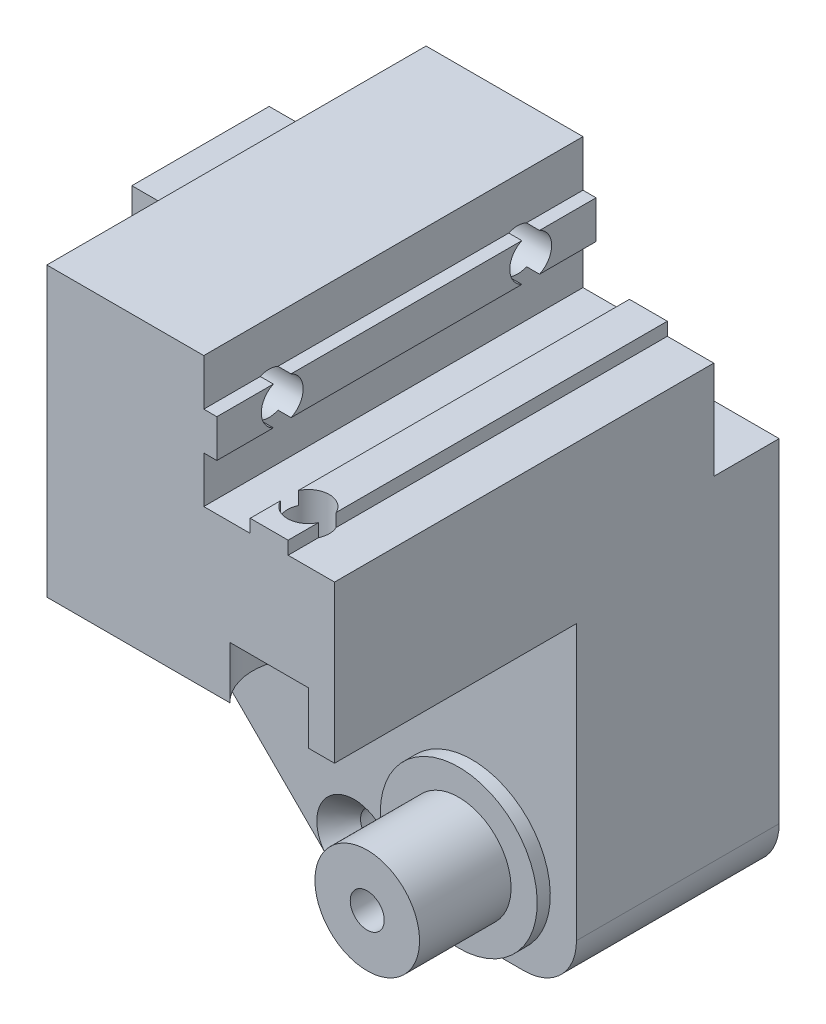
from build123d import *

# Parameters (mm, degrees)
BASE_SKETCHUP_W                   = 34
BASE_SKETCHUP_H                   = 37
BASE_EXTRUSION_DEPTH              = 15.5
FIX_EXTRUSION_DEPTH               = 34
BALL_EXTRUSION_DEPTH              = 29
BALL_BEARING_BASE_SKETCHUP_R      = 6
BALL_BEARING_BASE_EXTRUSION_DEPTH = 1
BALL_BEARING_SKETCHUP_R           = 4
BALL_BEARING_EXTRUSION_DEPTH      = 7
BALL_BEARING_FIX_SKETCHUP_R       = 1.3
BALL_BEARING_FIX_HOLE_DEPTH       = 12
BOSS_EXTRU_5_DEPTH                = 11.5
BOSS_EXTRU_6_DEPTH                = 1
ESQUISSE13_W                      = 5
ESQUISSE13_H                      = 17.5
ENL_V_MAT_EXTRU_1_DEPTH           = 35
CONG_2_R                          = 4
ENL_V_MAT_EXTRU_2_DEPTH           = 16.5
CONG_4_R                          = 2
ESQUISSE16_R                      = 1.6
MAKERBEAMINTERIORHOLES1_DEPTH     = 23
ESQUISSE17_R                      = 4.25
MAKERBEAMINTERIORHOLES2_DEPTH     = 4
ESQUISSE18_R                      = 1.6
MAKERBEAMFRONTHOLE1_DEPTH         = 23
ESQUISSE19_R                      = 4.25
MAKERBEAMFRONTHOLE2_DEPTH         = 4
ESQUISSE20_W                      = 37
ESQUISSE20_H                      = 47
ENL_V_MAT_EXTRU_7_DEPTH           = 35


with BuildPart() as part:
    # Base Sketchup → Base Extrusion (new body)
    with BuildSketch(Plane.XY):
        Rectangle(BASE_SKETCHUP_W, BASE_SKETCHUP_H)
    extrude(amount=BASE_EXTRUSION_DEPTH)


with BuildPart() as body_2:
    # Fix Sketchup → Fix Extrusion (new body)
    with BuildSketch(Plane(origin=(0, 0, 0), x_dir=(-1, 0, 0), z_dir=(0, 0, -1))):
        Polygon((17, 18.5), (13.45, 18.5), (13.45, 19.5), (10.55, 19.5), (10.55, 18.5), (7, 18.5), (7, 22.05), (8, 22.05), (8, 24.95), (7, 24.95), (7, 28.5), (-5, 28.5), (-5, 6.5), (17, 6.5), align=None)
    extrude(amount=-FIX_EXTRUSION_DEPTH)


with BuildPart() as ball_extrusion_tool:
    # Ball Place Sketchup → Ball Extrusion (new body)
    with BuildSketch(Plane.XZ.offset(18.5)):
        Polygon((-12.25, 0), (-12.25, 8.25), (-11.75, 8.25), (-11.75, 9.25), (-12.25, 9.25), (-12.25, 11.5), (12.25, 11.5), (12.25, 9.25), (11.75, 9.25), (11.75, 8.25), (12.25, 8.25), (12.25, 0), align=None)
    extrude(amount=-BALL_EXTRUSION_DEPTH)


with BuildPart() as part_1:
    add(part.part)

    # Ball Extrusion: cut by ball_extrusion_tool
    add(ball_extrusion_tool.part, mode=Mode.SUBTRACT)

    # Esquisse12 → Fraisage pour vis à tête fraisée bombée #41 (revolve, cut)
    with BuildSketch(Plane(origin=(0, -16.5, 15.5), x_dir=(0, -1, 0), z_dir=(1, 0, 0))):
        Polygon((0, 0), (0, 15.5), (1.3, 15.5), (1.3, 1.791698794), (2.8575, 0), align=None)
    revolve(axis=Axis((0, -16.5, 21.85), (0, 0, -1)), mode=Mode.SUBTRACT)

    # Ball Bearing Base Sketchup → Ball Bearing Base Extrusion (add)
    with BuildSketch(Plane.XY.offset(15.5)):
        with Locations((-9, -12.5)):
            Circle(BALL_BEARING_BASE_SKETCHUP_R)
    extrude(amount=BALL_BEARING_BASE_EXTRUSION_DEPTH)

    # Ball Bearing Sketchup → Ball Bearing Extrusion (add)
    with BuildSketch(Plane.XY.offset(16.5)):
        with Locations((-9, -12.5)):
            Circle(BALL_BEARING_SKETCHUP_R)
    extrude(amount=BALL_BEARING_EXTRUSION_DEPTH)

    # Ball Bearing Fix Sketchup → Ball Bearing Fix Hole (cut)
    with BuildSketch(Plane.XY.offset(23.5)):
        with Locations((-9, -12.5)):
            Circle(BALL_BEARING_FIX_SKETCHUP_R)
    extrude(amount=-BALL_BEARING_FIX_HOLE_DEPTH, mode=Mode.SUBTRACT)



with BuildPart() as body_2_1:
    add(body_2.part)

    # Ball Extrusion: cut by ball_extrusion_tool
    add(ball_extrusion_tool.part, mode=Mode.SUBTRACT)


with BuildPart() as part_2:
    add(part_1.part)

    add(body_2_1.part)  # Boss.-Extru.5 merges body 2
    # Esquisse10 → Boss.-Extru.5 (add)
    with BuildSketch(Plane(origin=(0, 0, 11.5), x_dir=(-1, 0, 0), z_dir=(0, 0, -1))):
        with BuildLine():
            Line((12.25, -2), (12.25, 10.5))
            Line((12.25, 10.5), (-12.25, 10.5))
            Line((-12.25, 10.5), (-12.25, -2))
            ThreePointArc((-12.25, -2), (0, 10.25), (12.25, -2))
        make_face()
    extrude(amount=BOSS_EXTRU_5_DEPTH)

    # Esquisse11 → Boss.-Extru.6 (add)
    with BuildSketch(Plane(origin=(0, 0, 8.25), x_dir=(-1, 0, 0), z_dir=(0, 0, -1))):
        with BuildLine():
            Line((11.75, -2), (12.25, -2))
            Line((12.25, -2), (12.25, 10.25))
            Line((12.25, 10.25), (-12.25, 10.25))
            Line((-12.25, 10.25), (-12.25, -2))
            Line((-12.25, -2), (-11.75, -2))
            ThreePointArc((-11.75, -2), (0, 9.75), (11.75, -2))
        make_face()
    extrude(amount=-BOSS_EXTRU_6_DEPTH)

    # Esquisse13 → Enlèv. mat.-Extru.1 (cut, through all)
    with BuildSketch(Plane(origin=(17, 0, 0), x_dir=(0, 0, -1), z_dir=(1, 0, 0))):
        with Locations((-2.5, 19.75)):
            Rectangle(ESQUISSE13_W, ESQUISSE13_H)
    extrude(amount=-ENL_V_MAT_EXTRU_1_DEPTH, mode=Mode.SUBTRACT)

    # Congé2
    cong_2_edges = [part_2.edges().sort_by_distance(p)[0] for p in [
        (-17, -18.5, 7.75),
    ]]
    fillet(cong_2_edges, radius=CONG_2_R)

    # Esquisse14 → Enlèv. mat.-Extru.2 (cut, through all)
    with BuildSketch(Plane.XY.offset(15.5)):
        Polygon((2, -18.5), (17, -3.5), (17, -18.5), align=None)
    extrude(amount=-ENL_V_MAT_EXTRU_2_DEPTH, mode=Mode.SUBTRACT)

    # Congé4
    cong_4_edges = [part_2.edges().sort_by_distance(p)[0] for p in [
        (17, -3.5, 7.75),
    ]]
    fillet(cong_4_edges, radius=CONG_4_R)

    # Esquisse16 → MakerBeamInteriorHoles1 (cut, through all)
    with BuildSketch(Plane(origin=(5, 0, 0), x_dir=(0, 0, -1), z_dir=(1, 0, 0))):
        with Locations((-29, 23.5)):
            Circle(ESQUISSE16_R)
        with Locations((-10, 23.5)):
            Circle(ESQUISSE16_R)
    extrude(amount=-MAKERBEAMINTERIORHOLES1_DEPTH, mode=Mode.SUBTRACT)

    # Esquisse17 → MakerBeamInteriorHoles2 (cut)
    with BuildSketch(Plane(origin=(5, 0, 0), x_dir=(0, 0, -1), z_dir=(1, 0, 0))):
        with Locations((-29, 23.5)):
            Circle(ESQUISSE17_R)
        with Locations((-10, 23.5)):
            Circle(ESQUISSE17_R)
    extrude(amount=-MAKERBEAMINTERIORHOLES2_DEPTH, mode=Mode.SUBTRACT)

    # Esquisse18 → MakerBeamFrontHole1 (cut, through all)
    with BuildSketch(Plane(origin=(0, 6.5, 0), x_dir=(-1, 0, 0), z_dir=(0, -1, 0))):
        with Locations((12, -31)):
            Circle(ESQUISSE18_R)
    extrude(amount=-MAKERBEAMFRONTHOLE1_DEPTH, mode=Mode.SUBTRACT)

    # Esquisse19 → MakerBeamFrontHole2 (cut)
    with BuildSketch(Plane(origin=(0, 6.5, 0), x_dir=(-1, 0, 0), z_dir=(0, -1, 0))):
        with Locations((12, -31)):
            Circle(ESQUISSE19_R)
    extrude(amount=-MAKERBEAMFRONTHOLE2_DEPTH, mode=Mode.SUBTRACT)


with BuildPart() as body_2_2:
    # Symétrie2: mirrored copy
    add(part_2.part.mirror(Plane(origin=(20, 0, 0), x_dir=(0, 0, 1), z_dir=(1, 0, 0))))


with BuildPart() as part_3:
    add(part_2.part)

    # Esquisse20 → Enlèv. mat.-Extru.7 (cut, through all)
    with BuildSketch(Plane.XY.offset(34)):
        with Locations((1.5, 5)):
            Rectangle(ESQUISSE20_W, ESQUISSE20_H)
    extrude(amount=-ENL_V_MAT_EXTRU_7_DEPTH, mode=Mode.SUBTRACT)


solid = body_2_2.part
